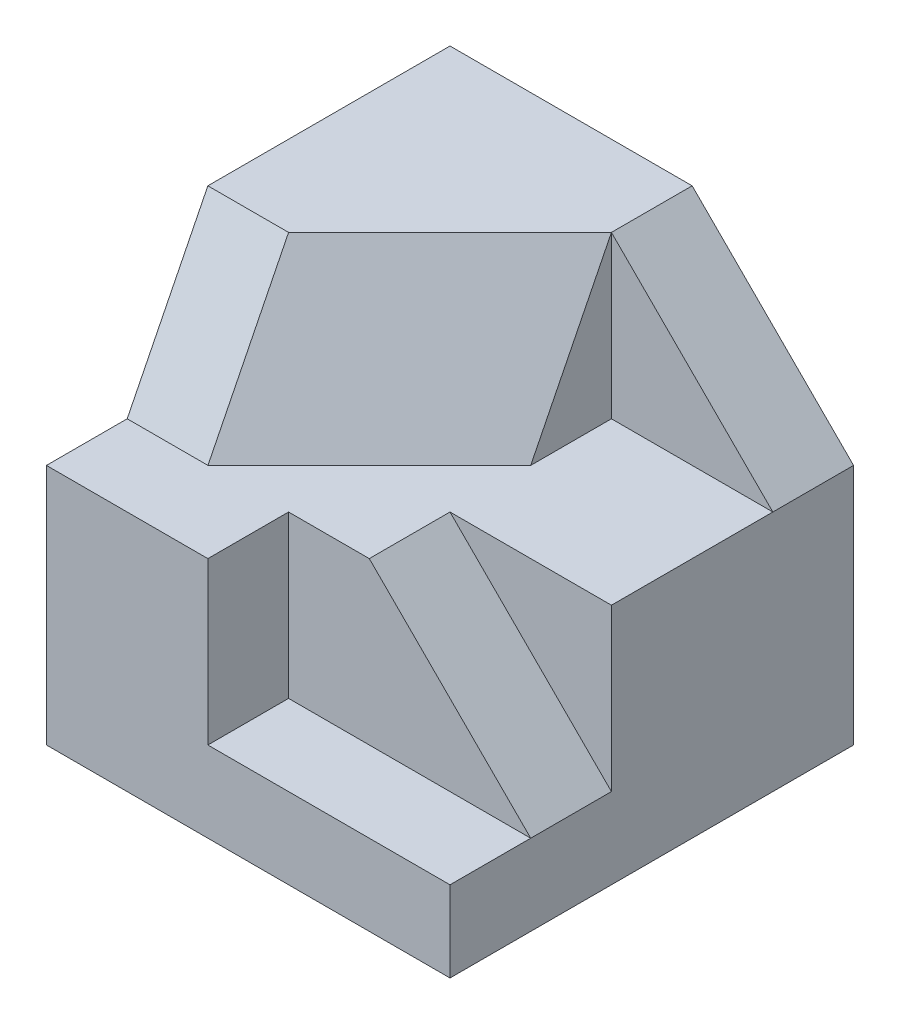
from build123d import *

# Parameters (mm, degrees)
SKETCH1_W           = 5
SKETCH1_H           = 5
BOSS_EXTRUDE1_DEPTH = 5
CUT_EXTRUDE2_DEPTH  = 2
CUT_EXTRUDE3_DEPTH  = 2
CUT_EXTRUDE4_DEPTH  = 2
SKETCH6_W           = 3
SKETCH6_H           = 2
CUT_EXTRUDE5_DEPTH  = 1
CUT_EXTRUDE6_DEPTH  = 1
CUT_EXTRUDE7_DEPTH  = 1
CUT_EXTRUDE8_DEPTH  = 3


with BuildPart() as part:
    # Sketch1 → Boss-Extrude1 (new body)
    with BuildSketch(Plane.XY):
        Rectangle(SKETCH1_W, SKETCH1_H)
    extrude(amount=BOSS_EXTRUDE1_DEPTH)

    # Sketch3 → Cut-Extrude2 (cut)
    with BuildSketch(Plane(origin=(0, 2.5, 0), x_dir=(1, 0, 0), z_dir=(0, 1, 0))):
        Polygon((-2.5, -5), (-2.5, -3.999504656), (-0.5, -3.999504656), (-0.5, -3), (0.5, -3), (0.5, -1), (2.5, -1), (2.5, -5), align=None)
    extrude(amount=-CUT_EXTRUDE2_DEPTH, mode=Mode.SUBTRACT)

    # Sketch4 → Cut-Extrude3 (cut)
    with BuildSketch(Plane(origin=(-0.5, 0, 0), x_dir=(0, 0, -1), z_dir=(1, 0, 0))):
        Polygon((-3, 2.5), (-3.999504656, 0.5), (-3.999504656, 2.5), align=None)
    extrude(amount=-CUT_EXTRUDE3_DEPTH, mode=Mode.SUBTRACT)

    # Sketch5 → Cut-Extrude4 (cut)
    with BuildSketch(Plane.XY.offset(1)):
        Polygon((0.5, 2.5), (2.5, 0.5), (2.5, 2.5), align=None)
    extrude(amount=-CUT_EXTRUDE4_DEPTH, mode=Mode.SUBTRACT)

    # Sketch6 → Cut-Extrude5 (cut)
    with BuildSketch(Plane.XY.offset(5)):
        with Locations((1, -0.5)):
            Rectangle(SKETCH6_W, SKETCH6_H)
    extrude(amount=-CUT_EXTRUDE5_DEPTH, mode=Mode.SUBTRACT)

    # Sketch7 → Cut-Extrude6 (cut)
    with BuildSketch(Plane.XY.offset(4)):
        Polygon((2.5, 0.5), (0.5, 0.5), (2.5, -1.5), align=None)
    extrude(amount=-CUT_EXTRUDE6_DEPTH, mode=Mode.SUBTRACT)

    # Sketch11 → Cut-Extrude7 (cut)
    with BuildSketch(Plane(origin=(1.222222222, 0.611111111, 1.222222222), x_dir=(0.745355992, -0.298142397, -0.596284794), z_dir=(0.666666667, 0.333333333, 0.666666667))):
        Polygon((-0.96896279, 1.788854382), (-3.652244363, 0.894427191), (-3.652244363, -1.341419262), (-0.96896279, -0.447213595), align=None)
    extrude(amount=CUT_EXTRUDE7_DEPTH, mode=Mode.SUBTRACT)

    # Sketch12 → Cut-Extrude8 (cut, through all)
    with BuildSketch(Plane(origin=(0, 0.5, 0), x_dir=(1, 0, 0), z_dir=(0, 1, 0))):
        Polygon((0.5, -2), (-1.5, -3.999504656), (0.5, -4), align=None)
    extrude(amount=CUT_EXTRUDE8_DEPTH, mode=Mode.SUBTRACT)


solid = part.part
